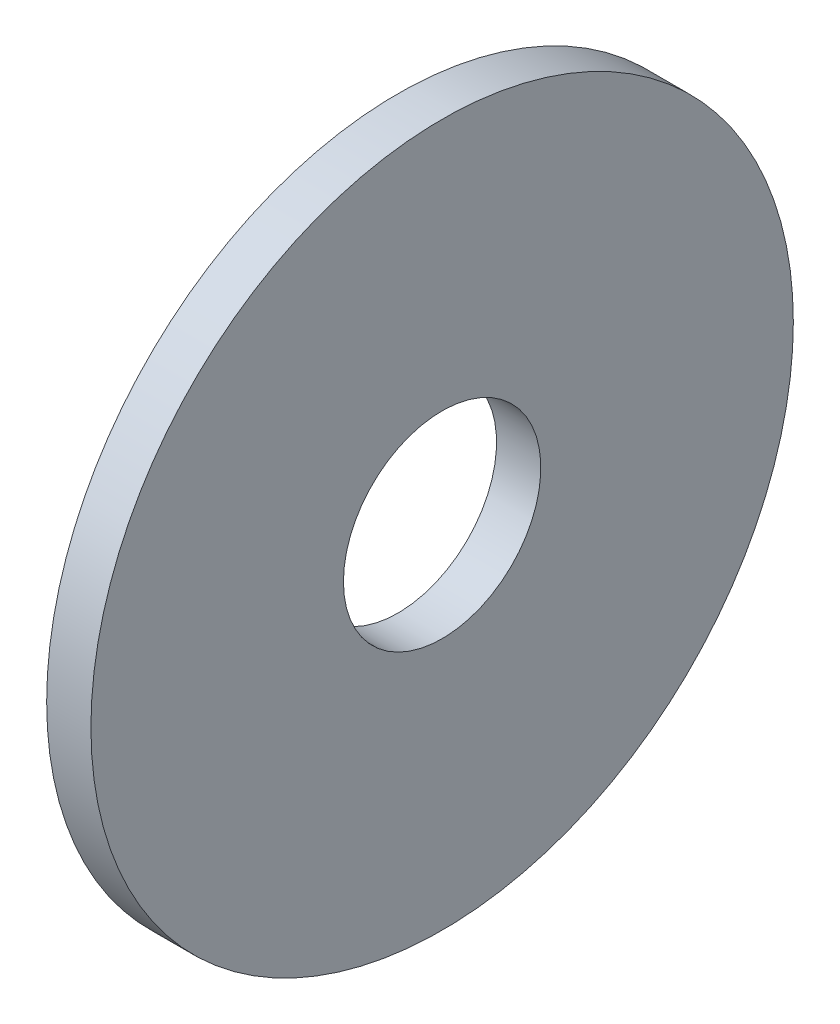
from build123d import *

# Parameters (mm, degrees)
SKETCH1_W = 1.6002
SKETCH1_H = 9.1313


with BuildPart() as part:
    # Sketch1 → Base-Revolve (revolve)
    with BuildSketch(Plane.XY):
        with Locations((-0.8001, 8.13435)):
            Rectangle(SKETCH1_W, SKETCH1_H)
    revolve(axis=Axis((-34.925, 0, 0), (1, 0, 0)))


solid = part.part
